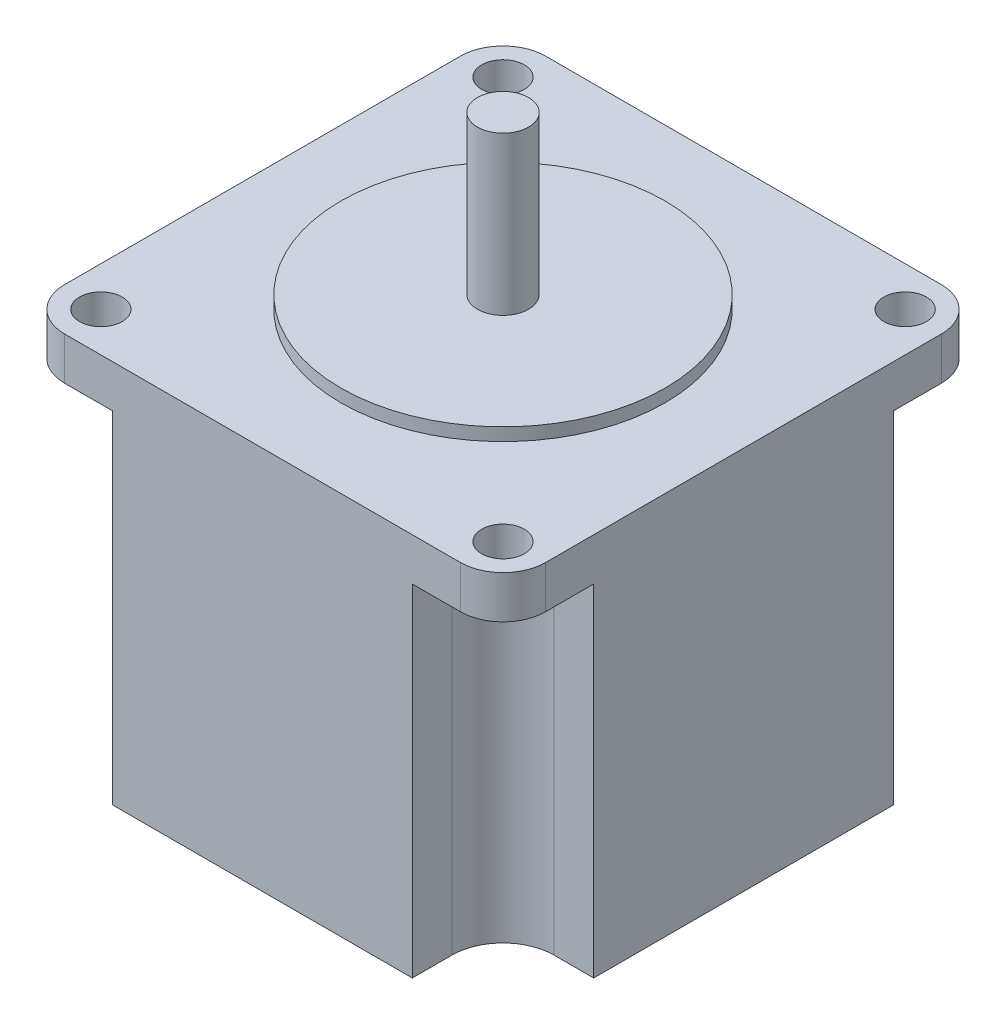
from build123d import *

# Parameters (mm, degrees)
BOSS_EXTRUDE1_DEPTH     = 45
SKETCH3_OUTSIDE_W       = 76.716
SKETCH3_OUTSIDE_H       = 76.716
CUT_EXTRUDE1_DEPTH      = 40
SKETCH4_R               = 2.5
CUT_EXTRUDE3_DEPTH      = 46
CUT_EXTRUDE3_DEPTH_BACK = 1
SKETCH5_R               = 19
BOSS_EXTRUDE2_DEPTH     = 1.5
SKETCH6_R               = 3
BOSS_EXTRUDE3_DEPTH     = 18.5


with BuildPart() as part:
    # Sketch2 → Boss-Extrude1 (new body)
    with BuildSketch(Plane(origin=(0, 0, 0), x_dir=(1, 0, 0), z_dir=(0, 1, 0))):
        with BuildLine():
            Line((-28.2, -23.2), (-28.2, 23.2))
            ThreePointArc((-28.2, 23.2), (-26.735533906, 26.735533906), (-23.2, 28.2))
            Line((-23.2, 28.2), (23.2, 28.2))
            ThreePointArc((23.2, 28.2), (26.735533906, 26.735533906), (28.2, 23.2))
            Line((28.2, 23.2), (28.2, -23.2))
            ThreePointArc((28.2, -23.2), (26.735533906, -26.735533906), (23.2, -28.2))
            Line((23.2, -28.2), (-23.2, -28.2))
            ThreePointArc((-23.2, -28.2), (-26.735533906, -26.735533906), (-28.2, -23.2))
        make_face()
    extrude(amount=BOSS_EXTRUDE1_DEPTH)

    # Sketch3 outside → Cut-Extrude1 (cut)
    with BuildSketch(Plane.XZ):
        Rectangle(SKETCH3_OUTSIDE_W, SKETCH3_OUTSIDE_H)
        with BuildLine():
            Line((-28.2, 17.57), (-23.57, 17.57))
            ThreePointArc((-23.57, 17.57), (-19.327359313, 19.327359313), (-17.57, 23.57))
            Line((-17.57, 23.57), (-17.57, 28.2))
            Line((-17.57, 28.2), (17.57, 28.2))
            Line((17.57, 28.2), (17.57, 23.57))
            ThreePointArc((17.57, 23.57), (19.327359313, 19.327359313), (23.57, 17.57))
            Line((23.57, 17.57), (28.2, 17.57))
            Line((28.2, 17.57), (28.2, -17.57))
            Line((28.2, -17.57), (23.57, -17.57))
            ThreePointArc((23.57, -17.57), (19.327359313, -19.327359313), (17.57, -23.57))
            Line((17.57, -23.57), (17.57, -28.2))
            Line((17.57, -28.2), (-17.57, -28.2))
            Line((-17.57, -28.2), (-17.57, -23.57))
            ThreePointArc((-17.57, -23.57), (-19.327359313, -19.327359313), (-23.57, -17.57))
            Line((-23.57, -17.57), (-28.2, -17.57))
            Line((-28.2, -17.57), (-28.2, 17.57))
        make_face(mode=Mode.SUBTRACT)
    extrude(amount=-CUT_EXTRUDE1_DEPTH, mode=Mode.SUBTRACT)

    # Sketch4 → Cut-Extrude3 (cut, two sides)
    with BuildSketch(Plane(origin=(0, 0, 0), x_dir=(1, 0, 0), z_dir=(0, 1, 0))) as cut_extrude3_sk:
        with Locations((23.57, -23.57)):
            Circle(SKETCH4_R)
        with Locations((-23.57, -23.57)):
            Circle(SKETCH4_R)
        with Locations((23.57, 23.57)):
            Circle(SKETCH4_R)
        with Locations((-23.57, 23.57)):
            Circle(SKETCH4_R)
    extrude(amount=CUT_EXTRUDE3_DEPTH, mode=Mode.SUBTRACT)
    extrude(cut_extrude3_sk.sketch, amount=-CUT_EXTRUDE3_DEPTH_BACK, mode=Mode.SUBTRACT)

    # Sketch5 → Boss-Extrude2 (add)
    with BuildSketch(Plane(origin=(0, 45, 0), x_dir=(1, 0, 0), z_dir=(0, 1, 0))):
        Circle(SKETCH5_R)
    extrude(amount=BOSS_EXTRUDE2_DEPTH)

    # Sketch6 → Boss-Extrude3 (add)
    with BuildSketch(Plane(origin=(0, 46.5, 0), x_dir=(1, 0, 0), z_dir=(0, 1, 0))):
        Circle(SKETCH6_R)
    extrude(amount=BOSS_EXTRUDE3_DEPTH)


solid = part.part
